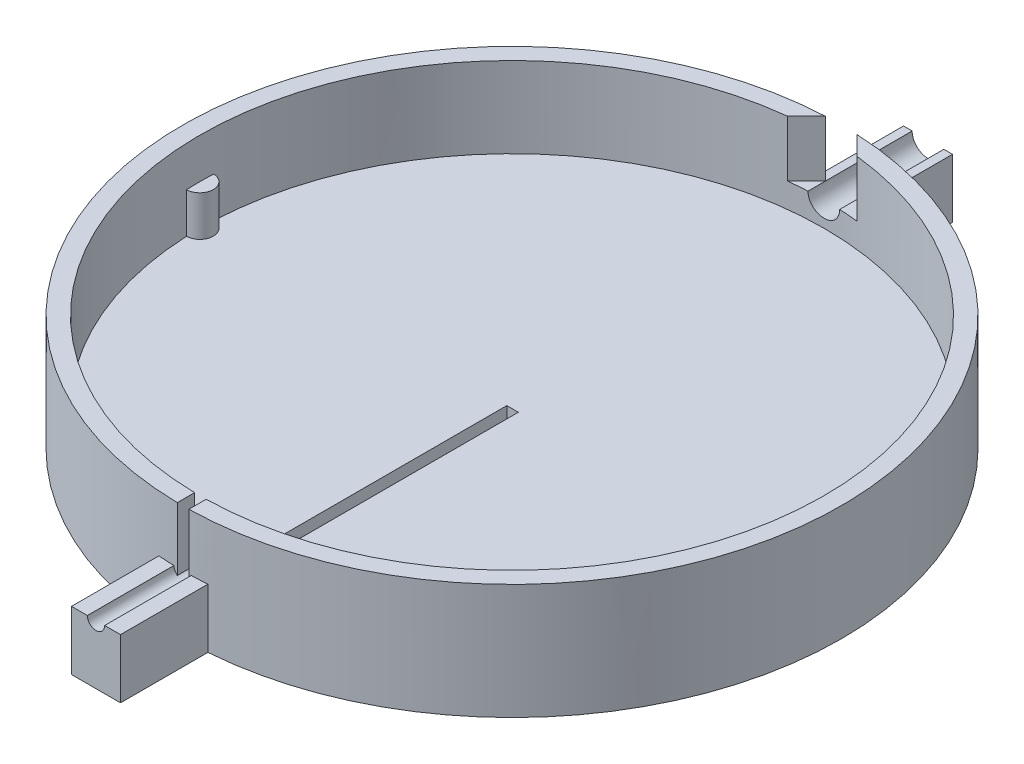
from build123d import *

# Parameters (mm, degrees)
SKETCH1_R           = 57.15
BOSS_EXTRUDE1_DEPTH = 20
SKETCH2_R           = 54.15
CUT_EXTRUDE1_DEPTH  = 14
BOSS_EXTRUDE2_DEPTH = 7
CUT_EXTRUDE2_DEPTH  = 84.260104492
SKETCH5_W           = 2
SKETCH5_H           = 16.000963959
CUT_EXTRUDE3_DEPTH  = 84.260104655
BOSS_EXTRUDE3_DEPTH = 18
BOSS_EXTRUDE4_DEPTH = 18
CUT_EXTRUDE4_DEPTH  = 9.75


with BuildPart() as part:
    # Sketch1 → Boss-Extrude1 (new body)
    with BuildSketch(Plane(origin=(0, 0, 0), x_dir=(1, 0, 0), z_dir=(0, 1, 0))):
        with Locations(Location((0, 0, 0), (0, 0, 270))):
            Circle(SKETCH1_R)
    extrude(amount=BOSS_EXTRUDE1_DEPTH)

    # Sketch2 → Cut-Extrude1 (cut)
    with BuildSketch(Plane(origin=(0, 20, 0), x_dir=(1, 0, 0), z_dir=(0, 1, 0))):
        with Locations(Location((0, 0, 0), (0, 0, 270))):
            Circle(SKETCH2_R)
    extrude(amount=-CUT_EXTRUDE1_DEPTH, mode=Mode.SUBTRACT)

    # Sketch3 → Boss-Extrude2 (add)
    with BuildSketch(Plane(origin=(0, 6, 0), x_dir=(1, 0, 0), z_dir=(0, 1, 0))):
        with BuildLine():
            ThreePointArc((-54.099007387, -2.349446691), (-51.8, 0), (-54.099007387, 2.349446691))
            ThreePointArc((-54.099007387, 2.349446691), (-54.15, 0), (-54.099007387, -2.349446691))
        make_face()
        with BuildLine():
            ThreePointArc((54.099007387, 2.349446691), (51.8, 0), (54.099007387, -2.349446691))
            ThreePointArc((54.099007387, -2.349446691), (54.15, 0), (54.099007387, 2.349446691))
        make_face()
    extrude(amount=BOSS_EXTRUDE2_DEPTH)

    # Sketch4 → Cut-Extrude2 (cut, through all)
    with BuildSketch(Plane.XY):
        with BuildLine():
            Line((2.75, 10.25), (2.75, 20))
            Line((2.75, 20), (-2.75, 20))
            Line((-2.75, 20), (-2.75, 10.25))
            ThreePointArc((-2.75, 10.25), (0, 7.5), (2.75, 10.25))
        make_face()
    extrude(amount=-CUT_EXTRUDE2_DEPTH, mode=Mode.SUBTRACT)

    # Sketch5 → Cut-Extrude3 (cut, through all)
    with BuildSketch(Plane.XY):
        with Locations((0.098176677, 11.999518021)):
            Rectangle(SKETCH5_W, SKETCH5_H)
    extrude(amount=CUT_EXTRUDE3_DEPTH, mode=Mode.SUBTRACT)

    # Sketch6 → Boss-Extrude3 (add)
    with BuildSketch(Plane.XY.offset(-54.15)):
        with BuildLine():
            Line((-4.25, 0), (4.25, 0))
            Line((4.25, 0), (4.25, 10.25))
            Line((4.25, 10.25), (2.75, 10.25))
            ThreePointArc((2.75, 10.25), (0, 7.5), (-2.75, 10.25))
            Line((-2.75, 10.25), (-4.25, 10.25))
            Line((-4.25, 10.25), (-4.25, 0))
        make_face()
    extrude(amount=-BOSS_EXTRUDE3_DEPTH)

    # Sketch7 → Boss-Extrude4 (add)
    with BuildSketch(Plane(origin=(0, 0, 54.15), x_dir=(-1, 0, 0), z_dir=(0, 0, -1))):
        with BuildLine():
            Line((4.25, 10.25), (1.5, 10.25))
            ThreePointArc((1.5, 10.25), (0, 8.75), (-1.5, 10.25))
            Line((-1.5, 10.25), (-4.25, 10.25))
            Line((-4.25, 10.25), (-4.25, 0))
            Line((-4.25, 0), (4.25, 0))
            Line((4.25, 0), (4.25, 10.25))
        make_face()
    extrude(amount=-BOSS_EXTRUDE4_DEPTH)

    # Sketch8 → Cut-Extrude4 (cut)
    with BuildSketch(Plane(origin=(0, 20, 0), x_dir=(1, 0, 0), z_dir=(0, 1, 0))):
        with BuildLine():
            Line((2.75, 54.080125739), (2.75, 57.083798052))
            Line((2.75, 57.083798052), (6.019401193, 53.814396859))
            ThreePointArc((6.019401193, 53.814396859), (4.386713152, 53.972022824), (2.75, 54.080125739))
        make_face()
        with BuildLine():
            Line((-2.75, 54.080125739), (-2.75, 57.083798052))
            Line((-2.75, 57.083798052), (-6.019401193, 53.814396859))
            ThreePointArc((-6.019401193, 53.814396859), (-4.386713152, 53.972022824), (-2.75, 54.080125739))
        make_face()
    extrude(amount=-CUT_EXTRUDE4_DEPTH, mode=Mode.SUBTRACT)


solid = part.part
